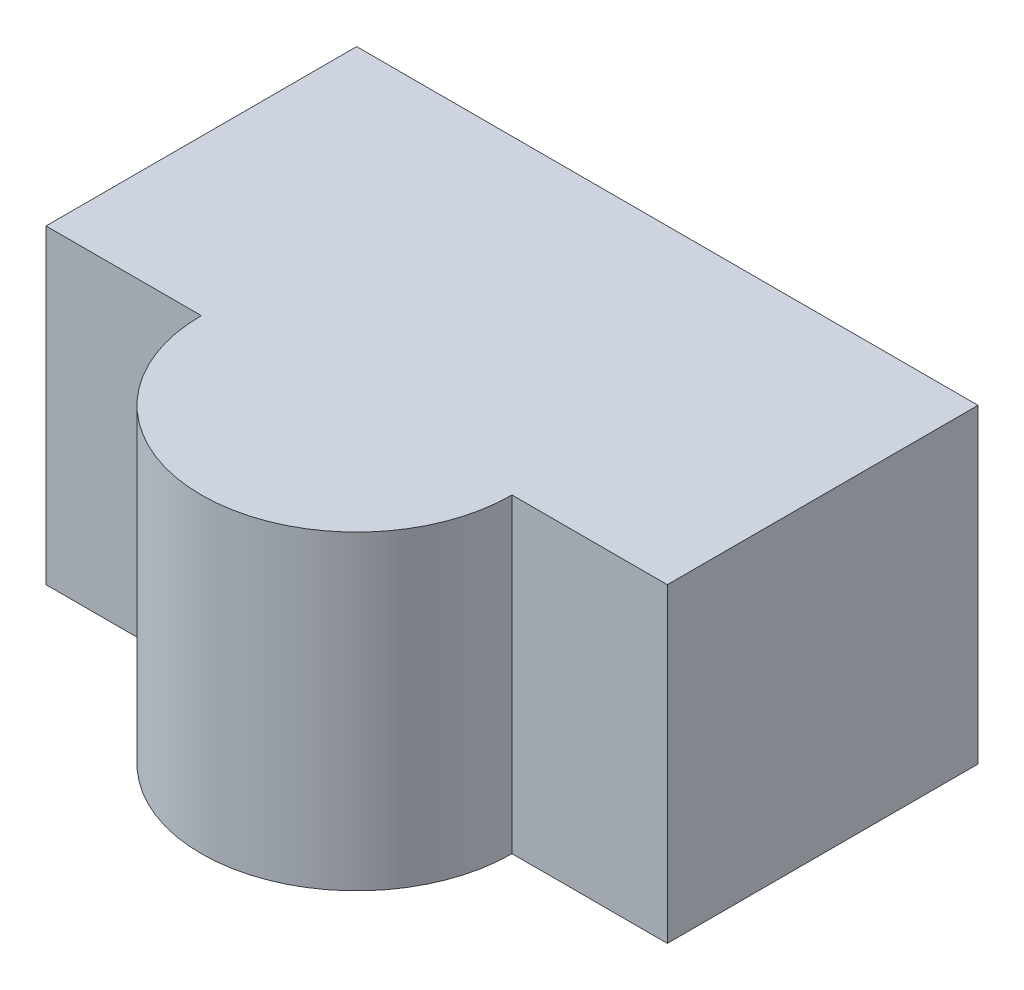
from build123d import *

# Parameters (mm, degrees)
CROQUIS1_W              = 40
CROQUIS1_H              = 20
SALIENTE_EXTRUIR1_DEPTH = 20
SALIENTE_EXTRUIR2_DEPTH = 20


with BuildPart() as part:
    # Croquis1 → Saliente-Extruir1 (new body)
    with BuildSketch(Plane(origin=(0, 0, 0), x_dir=(1, 0, 0), z_dir=(0, 1, 0))):
        Rectangle(CROQUIS1_W, CROQUIS1_H)
    extrude(amount=SALIENTE_EXTRUIR1_DEPTH)

    # Croquis2 → Saliente-Extruir2 (add)
    with BuildSketch(Plane(origin=(0, 20, 0), x_dir=(1, 0, 0), z_dir=(0, 1, 0))):
        with BuildLine():
            Line((-10, -10), (10, -10))
            ThreePointArc((10, -10), (0, -20), (-10, -10))
        make_face()
    extrude(amount=-SALIENTE_EXTRUIR2_DEPTH)


solid = part.part
